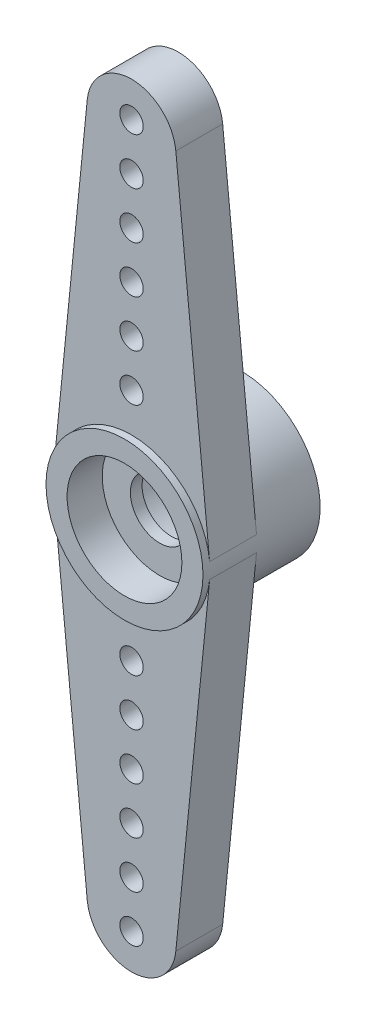
from build123d import *

# Parameters (mm, degrees)
EXTRUDE_1_DEPTH     = 2
SKETCH_2_R          = 3.35
EXTRUDE_2_DEPTH     = 0.3
SKETCH_3_R          = 3.35
EXTRUDE_3_DEPTH     = 2.7
SKETCH_4_R          = 2.45
CUT_EXTRUDE_1_DEPTH = 1.5
SKETCH_5_R          = 1.25
CUT_EXTRUDE_2_DEPTH = 4.5
SKETCH_6_R          = 2.45
CUT_EXTRUDE_3_DEPTH = 3
SKETCH_7_R          = 0.5
CUT_EXTRUDE_4_DEPTH = 5.7


with BuildPart() as part:
    # Эскиз1 → Бобышка-Вытянуть1 (new body)
    with BuildSketch(Plane.XY):
        with BuildLine():
            Line((-3.333438, 0.332705), (-1.890606, 14.788699))
            ThreePointArc((-1.890606, 14.788699), (0, 16.5), (1.890606, 14.788699))
            Line((1.890606, 14.788699), (3.333438, 0.332705))
            ThreePointArc((3.333438, 0.332705), (3.35, 0), (3.333438, -0.332705))
            Line((3.333438, -0.332705), (1.890606, -14.788699))
            ThreePointArc((1.890606, -14.788699), (0, -16.5), (-1.890606, -14.788699))
            Line((-1.890606, -14.788699), (-3.333438, -0.332705))
            ThreePointArc((-3.333438, -0.332705), (-3.35, 0), (-3.333438, 0.332705))
        make_face()
    extrude(amount=EXTRUDE_1_DEPTH)

    # Эскиз2 → Бобышка-Вытянуть2 (add)
    with BuildSketch(Plane.XY.offset(2)):
        Circle(SKETCH_2_R)
    extrude(amount=EXTRUDE_2_DEPTH)

    # Эскиз3 → Бобышка-Вытянуть3 (add)
    with BuildSketch(Plane(origin=(0, 0, 0), x_dir=(-1, 0, 0), z_dir=(0, 0, -1))):
        Circle(SKETCH_3_R)
    extrude(amount=EXTRUDE_3_DEPTH)

    # Эскиз4 → Вырез-Вытянуть1 (cut)
    with BuildSketch(Plane.XY.offset(2.3)):
        Circle(SKETCH_4_R)
    extrude(amount=-CUT_EXTRUDE_1_DEPTH, mode=Mode.SUBTRACT)

    # Эскиз5 → Вырез-Вытянуть2 (cut, through all)
    with BuildSketch(Plane.XY.offset(0.8)):
        Circle(SKETCH_5_R)
    extrude(amount=-CUT_EXTRUDE_2_DEPTH, mode=Mode.SUBTRACT)

    # Эскиз6 → Вырез-Вытянуть3 (cut)
    with BuildSketch(Plane(origin=(0, 0, -2.7), x_dir=(-1, 0, 0), z_dir=(0, 0, -1))):
        Circle(SKETCH_6_R)
    extrude(amount=-CUT_EXTRUDE_3_DEPTH, mode=Mode.SUBTRACT)

    # Эскиз7 → Вырез-Вытянуть4 (cut, through all)
    with BuildSketch(Plane.XY.offset(2)):
        with Locations((0, 15)):
            Circle(SKETCH_7_R)
        with Locations((0, -15)):
            Circle(SKETCH_7_R)
        with Locations((0, -5)):
            Circle(SKETCH_7_R)
        with Locations((0, 5)):
            Circle(SKETCH_7_R)
        with Locations((0, -7)):
            Circle(SKETCH_7_R)
        with Locations((0, 7)):
            Circle(SKETCH_7_R)
        with Locations((0, -9)):
            Circle(SKETCH_7_R)
        with Locations((0, -11)):
            Circle(SKETCH_7_R)
        with Locations((0, 9)):
            Circle(SKETCH_7_R)
        with Locations((0, 11)):
            Circle(SKETCH_7_R)
        with Locations((0, 13)):
            Circle(SKETCH_7_R)
        with Locations((0, -13)):
            Circle(SKETCH_7_R)
    extrude(amount=-CUT_EXTRUDE_4_DEPTH, mode=Mode.SUBTRACT)


solid = part.part
